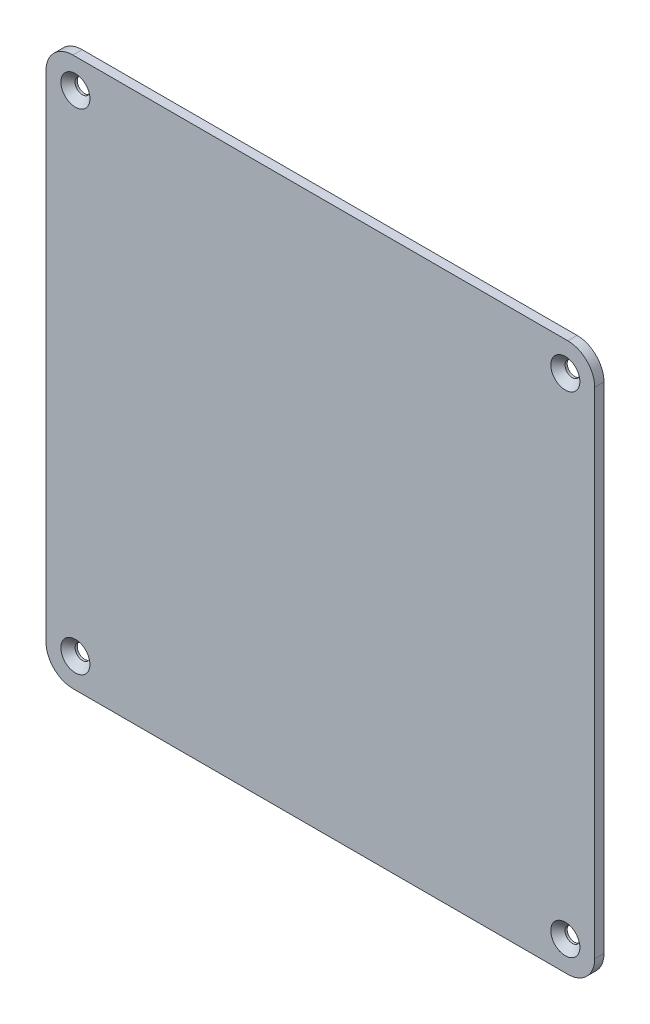
from build123d import *

# Parameters (mm, degrees)
BOSS_EXTRUDE1_DEPTH                            = 3
CSK_FOR_M4_FLAT_HEAD_MACHINE_SCREW1_AT_2_COUNT = 2
CSK_FOR_M4_FLAT_HEAD_MACHINE_SCREW1_AT_2_PITCH = 158.4
CSK_FOR_M4_FLAT_HEAD_MACHINE_SCREW1_AT_3_COUNT = 2
CSK_FOR_M4_FLAT_HEAD_MACHINE_SCREW1_AT_3_PITCH = 224.01142828
CSK_FOR_M4_FLAT_HEAD_MACHINE_SCREW1_AT_4_COUNT = 2
CSK_FOR_M4_FLAT_HEAD_MACHINE_SCREW1_AT_4_PITCH = 158.4


with BuildPart() as part:
    # Sketch1 → Boss-Extrude1 (new body)
    with BuildSketch(Plane.XY):
        with BuildLine():
            Line((-88.7, 80), (-88.7, -80))
            ThreePointArc((-88.7, -80), (-86.151828996, -86.151828996), (-80, -88.7))
            Line((-80, -88.7), (80, -88.7))
            ThreePointArc((80, -88.7), (86.151828996, -86.151828996), (88.7, -80))
            Line((88.7, -80), (88.7, 80))
            ThreePointArc((88.7, 80), (86.151828996, 86.151828996), (80, 88.7))
            Line((80, 88.7), (-80, 88.7))
            ThreePointArc((-80, 88.7), (-86.151828996, 86.151828996), (-88.7, 80))
        make_face()
    extrude(amount=-BOSS_EXTRUDE1_DEPTH)

    # Sketch3 → CSK for M4 Flat Head Machine Screw1 (revolve, cut)
    with BuildSketch(Plane(origin=(-79.2, 79.2, 0), x_dir=(0, -1, 0), z_dir=(1, 0, 0))):
        Polygon((0, 0), (0, 3), (2.4, 3), (2.4, 2.3), (4.7, 0), align=None)
    csk_for_m4_flat_head_machine_screw1 = revolve(axis=Axis((-79.2, 79.2, 6.35), (0, 0, -1)), mode=Mode.SUBTRACT)

    # CSK for M4 Flat Head Machine Screw1 at 2: CSK for M4 Flat Head Machine Screw1 ×2
    with Locations(*[(i * CSK_FOR_M4_FLAT_HEAD_MACHINE_SCREW1_AT_2_PITCH, 0, 0) for i in range(1, CSK_FOR_M4_FLAT_HEAD_MACHINE_SCREW1_AT_2_COUNT)]):
        add(csk_for_m4_flat_head_machine_screw1, mode=Mode.SUBTRACT)

    # CSK for M4 Flat Head Machine Screw1 at 3: CSK for M4 Flat Head Machine Screw1 ×2
    with Locations(*[Vector(0.707106781, -0.707106781, 0) * (i * CSK_FOR_M4_FLAT_HEAD_MACHINE_SCREW1_AT_3_PITCH) for i in range(1, CSK_FOR_M4_FLAT_HEAD_MACHINE_SCREW1_AT_3_COUNT)]):
        add(csk_for_m4_flat_head_machine_screw1, mode=Mode.SUBTRACT)

    # CSK for M4 Flat Head Machine Screw1 at 4: CSK for M4 Flat Head Machine Screw1 ×2
    with Locations(*[(0, -i * CSK_FOR_M4_FLAT_HEAD_MACHINE_SCREW1_AT_4_PITCH, 0) for i in range(1, CSK_FOR_M4_FLAT_HEAD_MACHINE_SCREW1_AT_4_COUNT)]):
        add(csk_for_m4_flat_head_machine_screw1, mode=Mode.SUBTRACT)


solid = part.part
